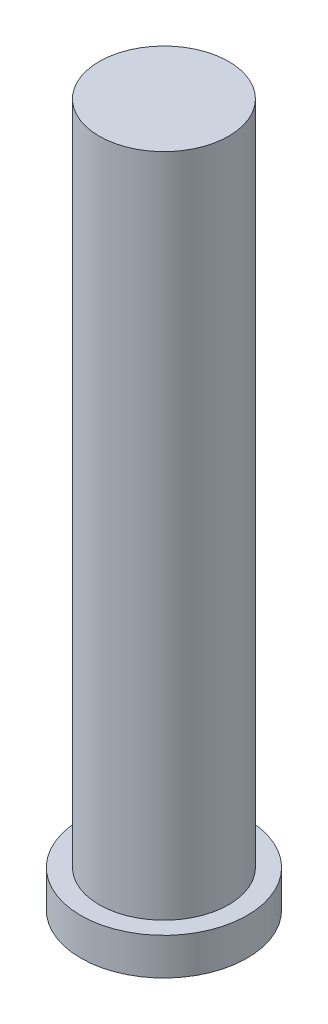
from build123d import *

# Parameters (mm, degrees)
SKETCH1_R           = 2.8575
BOSS_EXTRUDE1_DEPTH = 1.27
SKETCH2_R           = 2.2225
BOSS_EXTRUDE2_DEPTH = 22.86


with BuildPart() as part:
    # Sketch1 → Boss-Extrude1 (new body)
    with BuildSketch(Plane(origin=(0, 0, 0), x_dir=(1, 0, 0), z_dir=(0, 1, 0))):
        Circle(SKETCH1_R)
    extrude(amount=BOSS_EXTRUDE1_DEPTH)

    # Sketch2 → Boss-Extrude2 (add)
    with BuildSketch(Plane(origin=(0, 1.27, 0), x_dir=(1, 0, 0), z_dir=(0, 1, 0))):
        Circle(SKETCH2_R)
    extrude(amount=BOSS_EXTRUDE2_DEPTH)


solid = part.part
